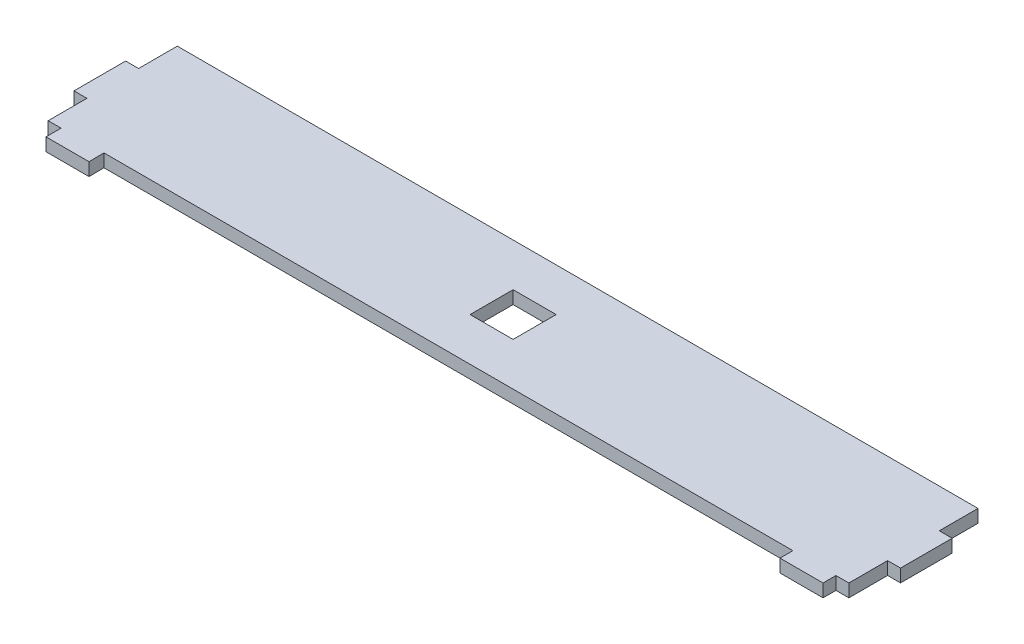
from build123d import *

# Parameters (mm, degrees)
SKETCH_4_W      = 10
SKETCH_4_H      = 10
EXTRUDE_1_DEPTH = 3


with BuildPart() as part:
    # 草图4 → 凸台-拉伸1 (new body)
    with BuildSketch(Plane(origin=(0, 0, 0), x_dir=(1, 0, 0), z_dir=(0, 1, 0))):
        Polygon((0, 30), (180, 30), (183, 30), (183, 21), (186, 21), (186, 9), (183, 9), (183, 0), (179.95, 0), (180, 0), (180, -3), (170, -3), (170, 0), (170.05, 0), (9.95, 0), (10, -3.504796537), (0, -3.504796537), (0, 0), (-3, 0), (-3, 9), (-6, 9), (-6, 21), (-3, 21), (-3, 30), align=None)
        with Locations((90, 15)):
            Rectangle(SKETCH_4_W, SKETCH_4_H, mode=Mode.SUBTRACT)
    extrude(amount=EXTRUDE_1_DEPTH)


solid = part.part
